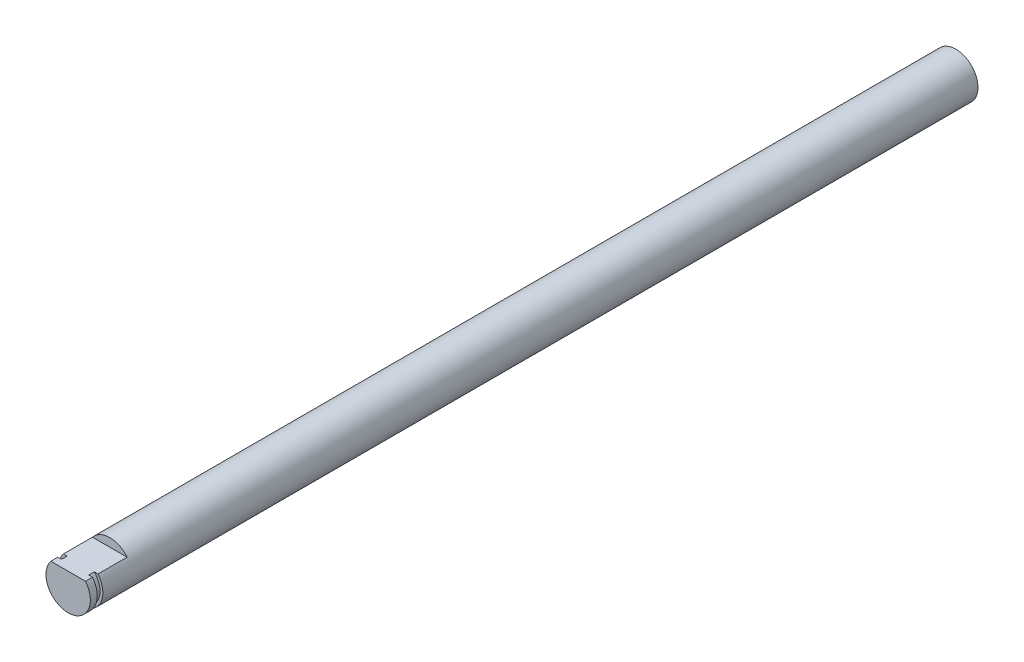
from build123d import *

# Parameters (mm, degrees)
SKETCH1_R           = 4
BOSS_EXTRUDE1_DEPTH = 160
CUT_EXTRUDE1_DEPTH  = 7.5
SKETCH3_R           = 4
SKETCH3_R_2         = 3.5
CUT_EXTRUDE2_DEPTH  = 1


with BuildPart() as part:
    # Sketch1 → Boss-Extrude1 (new body)
    with BuildSketch(Plane.XY):
        Circle(SKETCH1_R)
    extrude(amount=BOSS_EXTRUDE1_DEPTH)

    # Sketch2 → Cut-Extrude1 (cut)
    with BuildSketch(Plane.XY.offset(160)):
        with BuildLine():
            Line((3.122498999, 2.5), (-3.122498999, 2.5))
            ThreePointArc((-3.122498999, 2.5), (0, 4), (3.122498999, 2.5))
        make_face()
    extrude(amount=-CUT_EXTRUDE1_DEPTH, mode=Mode.SUBTRACT)

    # Sketch3 → Cut-Extrude2 (cut)
    with BuildSketch(Plane.XY.offset(158.75)):
        Circle(SKETCH3_R)
        Circle(SKETCH3_R_2, mode=Mode.SUBTRACT)
    extrude(amount=-CUT_EXTRUDE2_DEPTH, mode=Mode.SUBTRACT)


solid = part.part
